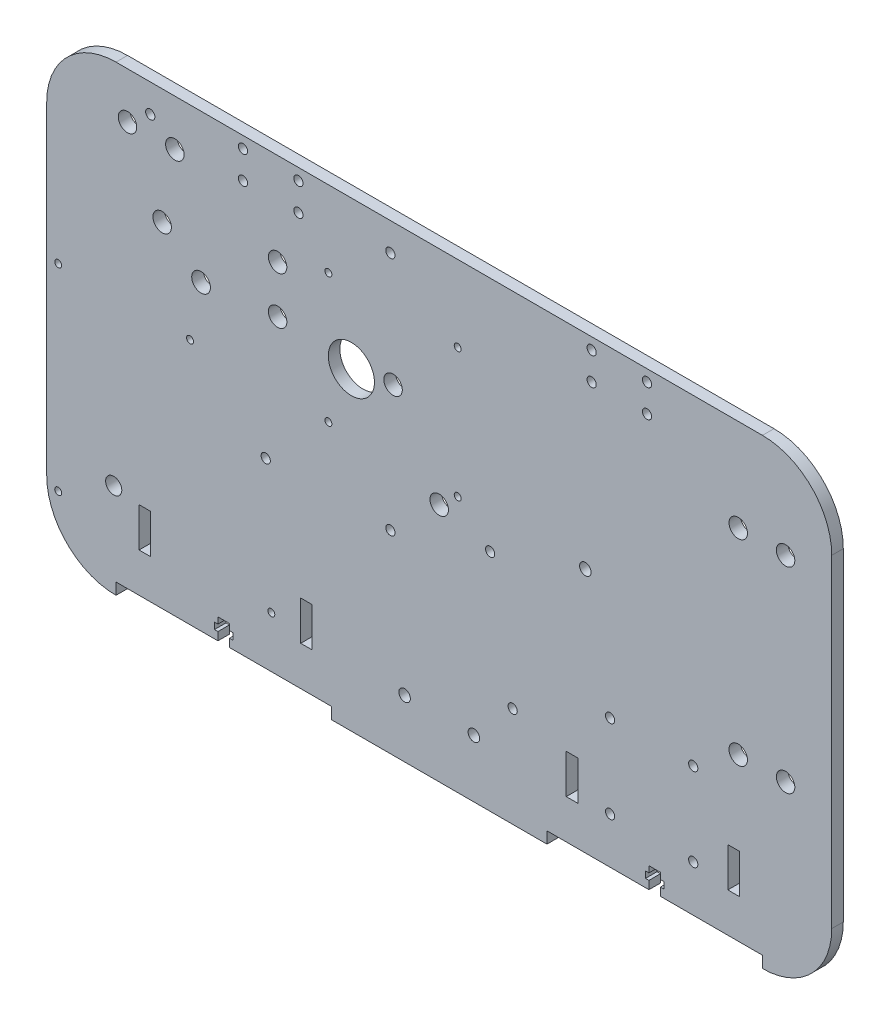
from build123d import *

# Parameters (mm, degrees)
SALIENTE_EXTRUIR1_DEPTH = 5
CROQUIS2_R              = 4
CORTAR_EXTRUIR4_DEPTH   = 10
CROQUIS3_R              = 2
CROQUIS3_R_2            = 10
CROQUIS3_R_3            = 4.05
CORTAR_EXTRUIR5_DEPTH   = 10
CROQUIS5_R              = 1.5
CORTAR_EXTRUIR6_DEPTH   = 10
CROQUIS6_R              = 2
CORTAR_EXTRUIR7_DEPTH   = 10
CROQUIS8_R              = 2
CORTAR_EXTRUIR8_DEPTH   = 10
CROQUIS9_R              = 3.5
CROQUIS9_R_2            = 1.5
CROQUIS9_R_3            = 2.5
CROQUIS9_R_4            = 2
CORTAR_EXTRUIR9_DEPTH   = 10
CROQUIS10_W             = 93.333333333
CROQUIS10_H             = 5
CORTAR_EXTRUIR10_DEPTH  = 10
CORTAR_EXTRUIR14_DEPTH  = 5
CROQUIS13_W             = 5
CROQUIS13_H             = 17
CORTAR_EXTRUIR15_DEPTH  = 5
CROQUIS14_R             = 2.5
CORTAR_EXTRUIR16_DEPTH  = 10


with BuildPart() as part:
    # Croquis1 → Saliente-Extruir1 (new body)
    with BuildSketch(Plane.XY):
        with BuildLine():
            Line((30, 0), (310, 0))
            ThreePointArc((310, 0), (331.213203436, 8.786796564), (340, 30))
            Line((340, 30), (340, 170))
            ThreePointArc((340, 170), (331.213203436, 191.213203436), (310, 200))
            Line((310, 200), (30, 200))
            ThreePointArc((30, 200), (8.786796564, 191.213203436), (0, 170))
            Line((0, 170), (0, 30))
            ThreePointArc((0, 30), (8.786796564, 8.786796564), (30, 0))
        make_face()
    extrude(amount=SALIENTE_EXTRUIR1_DEPTH)

    # Croquis2 → Cortar-Extruir4 (cut)
    with BuildSketch(Plane(origin=(0, 0, 5), x_dir=(-1, 0, 0), z_dir=(0, 0, -1))):
        with Locations((-55.5, 180)):
            Circle(CROQUIS2_R)
        with Locations((-35, 180)):
            Circle(CROQUIS2_R)
        with Locations((-100, 160)):
            Circle(CROQUIS2_R)
        with Locations((-100, 139.5)):
            Circle(CROQUIS2_R)
        with Locations((-299.5, 160)):
            Circle(CROQUIS2_R)
        with Locations((-320, 160)):
            Circle(CROQUIS2_R)
        with Locations((-320, 75)):
            Circle(CROQUIS2_R)
        with Locations((-299.5, 75)):
            Circle(CROQUIS2_R)
        with Locations((-150, 139)):
            Circle(CROQUIS2_R)
        with Locations((-170, 104)):
            Circle(CROQUIS2_R)
        with Locations((-50, 150)):
            Circle(CROQUIS2_R)
    extrude(amount=CORTAR_EXTRUIR4_DEPTH, mode=Mode.SUBTRACT)

    # Croquis3 → Cortar-Extruir5 (cut)
    with BuildSketch(Plane(origin=(0, 0, 0), x_dir=(-1, 0, 0), z_dir=(0, 0, -1))):
        with Locations((-148.85, 83.84)):
            Circle(CROQUIS3_R)
        with Locations((-94.85, 83.84)):
            Circle(CROQUIS3_R)
        with Locations((-44.85, 187.84)):
            Circle(CROQUIS3_R)
        with Locations((-148.85, 187.84)):
            Circle(CROQUIS3_R)
        with Locations((-131.95, 135.84)):
            Circle(CROQUIS3_R_2)
        with Locations((-66.85, 135.84)):
            Circle(CROQUIS3_R_3)
    extrude(amount=-CORTAR_EXTRUIR5_DEPTH, mode=Mode.SUBTRACT)

    # Croquis5 → Cortar-Extruir6 (cut)
    with BuildSketch(Plane(origin=(0, 0, 0), x_dir=(-1, 0, 0), z_dir=(0, 0, -1))):
        with Locations((-178, 167)):
            Circle(CROQUIS5_R)
        with Locations((-122, 111)):
            Circle(CROQUIS5_R)
        with Locations((-122, 167)):
            Circle(CROQUIS5_R)
        with Locations((-178, 111)):
            Circle(CROQUIS5_R)
    extrude(amount=-CORTAR_EXTRUIR6_DEPTH, mode=Mode.SUBTRACT)

    # Croquis6 → Cortar-Extruir7 (cut)
    with BuildSketch(Plane.XY.offset(5)):
        with Locations((244, 61)):
            Circle(CROQUIS6_R)
        with Locations((280, 61)):
            Circle(CROQUIS6_R)
        with Locations((244, 25)):
            Circle(CROQUIS6_R)
        with Locations((280, 25)):
            Circle(CROQUIS6_R)
    extrude(amount=-CORTAR_EXTRUIR7_DEPTH, mode=Mode.SUBTRACT)

    # Croquis8 → Cortar-Extruir8 (cut)
    with BuildSketch(Plane.XY.offset(5)):
        with Locations((236, 195)):
            Circle(CROQUIS8_R)
        with Locations((236, 183)):
            Circle(CROQUIS8_R)
        with Locations((260, 183)):
            Circle(CROQUIS8_R)
        with Locations((260, 195)):
            Circle(CROQUIS8_R)
        with Locations((85, 195)):
            Circle(CROQUIS8_R)
        with Locations((85, 183)):
            Circle(CROQUIS8_R)
        with Locations((109, 183)):
            Circle(CROQUIS8_R)
        with Locations((109, 195)):
            Circle(CROQUIS8_R)
    extrude(amount=-CORTAR_EXTRUIR8_DEPTH, mode=Mode.SUBTRACT)

    # Croquis9 → Cortar-Extruir9 (cut)
    with BuildSketch(Plane(origin=(0, 0, 0), x_dir=(-1, 0, 0), z_dir=(0, 0, -1))):
        with Locations((-29.01, 40.656502357)):
            Circle(CROQUIS9_R)
        with Locations((-62.080404779, 111.910005093)):
            Circle(CROQUIS9_R_2)
        with Locations((-4.98, 111.910005093)):
            Circle(CROQUIS9_R_2)
        with Locations((-97.280894834, 27.160005093)):
            Circle(CROQUIS9_R_2)
        with Locations((-4.98, 26.56)):
            Circle(CROQUIS9_R_2)
        with Locations((-233.296749654, 111.494889841)):
            Circle(CROQUIS9_R_3)
        with Locations((-201.8, 43.4)):
            Circle(CROQUIS9_R_4)
        with Locations((-192.05, 97.413240345)):
            Circle(CROQUIS9_R_4)
    extrude(amount=-CORTAR_EXTRUIR9_DEPTH, mode=Mode.SUBTRACT)

    # Croquis10 → Cortar-Extruir10 (cut)
    with BuildSketch(Plane.XY.offset(5)):
        with Locations((76.666666667, 2.5)):
            Rectangle(CROQUIS10_W, CROQUIS10_H)
        with Locations((263.333333334, 2.5)):
            Rectangle(CROQUIS10_W, CROQUIS10_H)
    extrude(amount=-CORTAR_EXTRUIR10_DEPTH, mode=Mode.SUBTRACT)

    # Croquis12 → Cortar-Extruir14 (cut)
    with BuildSketch(Plane.XY.offset(5)):
        Polygon((74.166666667, 5), (74.166666667, 8.5), (72.666666667, 8.5), (72.666666667, 11.3), (74.166666667, 11.3), (74.166666667, 14), (79.166666667, 14), (79.166666667, 11.3), (80.666666667, 11.3), (80.666666667, 8.5), (79.166666667, 8.5), (79.166666667, 5), align=None)
        Polygon((260.833333333, 11.3), (260.833333333, 14), (265.833333333, 14), (265.833333333, 11.3), (267.333333333, 11.3), (267.333333333, 8.5), (265.833333333, 8.5), (265.833333333, 5), (260.833333333, 5), (260.833333333, 8.5), (259.333333333, 8.5), (259.333333333, 11.3), align=None)
    extrude(amount=-CORTAR_EXTRUIR14_DEPTH, mode=Mode.SUBTRACT)

    # Croquis13 → Cortar-Extruir15 (cut)
    with BuildSketch(Plane.XY.offset(5)):
        with Locations((42.5, 30.5)):
            Rectangle(CROQUIS13_W, CROQUIS13_H)
        with Locations((112.5, 30.5)):
            Rectangle(CROQUIS13_W, CROQUIS13_H)
        with Locations((227.5, 30.5)):
            Rectangle(CROQUIS13_W, CROQUIS13_H)
        with Locations((297.5, 30.5)):
            Rectangle(CROQUIS13_W, CROQUIS13_H)
    extrude(amount=-CORTAR_EXTRUIR15_DEPTH, mode=Mode.SUBTRACT)

    # Croquis14 → Cortar-Extruir16 (cut)
    with BuildSketch(Plane.XY.offset(5)):
        with Locations((155, 25)):
            Circle(CROQUIS14_R)
        with Locations((185, 25)):
            Circle(CROQUIS14_R)
    extrude(amount=-CORTAR_EXTRUIR16_DEPTH, mode=Mode.SUBTRACT)


solid = part.part
